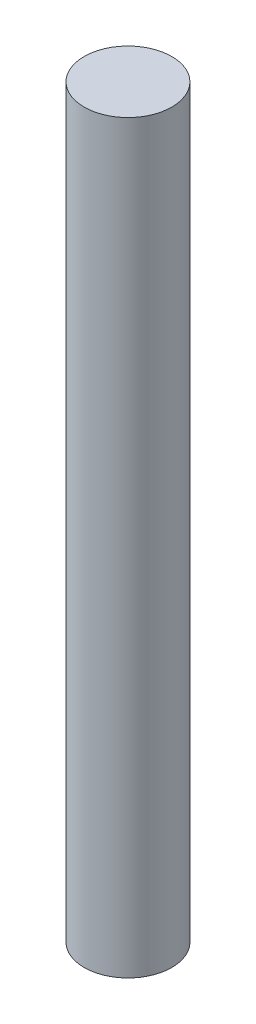
from build123d import *

# Parameters (mm, degrees)
ESQUISSE1_R        = 2
BOSS_EXTRU_1_DEPTH = 34


with BuildPart() as part:
    # Esquisse1 → Boss.-Extru.1 (new body)
    with BuildSketch(Plane(origin=(0, 0, 0), x_dir=(1, 0, 0), z_dir=(0, 1, 0))):
        Circle(ESQUISSE1_R)
    extrude(amount=BOSS_EXTRU_1_DEPTH)


solid = part.part
